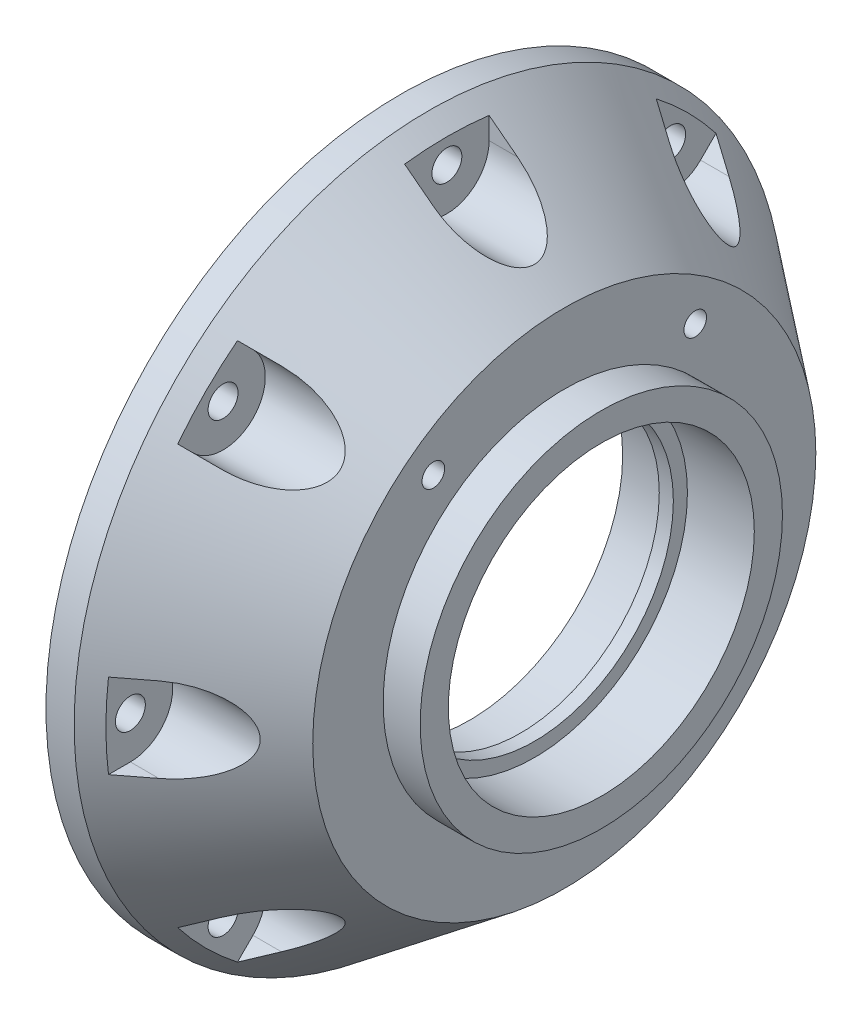
from build123d import *

# Parameters (mm, degrees)
FILLET1_R                       = 9.525
CUT_EXTRUDE1_START              = -10.414
CUT_EXTRUDE1_DEPTH              = 316.234767746
F_1_4_CLEARANCE_HOLE1_D         = 6.7564
F_1_4_20_TAPPED_HOLE1_D         = 5.1054
F_1_4_20_TAPPED_HOLE1_DEPTH     = 16.51
F_1_4_20_TAPPED_HOLE1_TIP       = 1.533816902
F_3_16_0_1875_DOWEL_HOLE1_D     = 4.7625
F_3_16_0_1875_DOWEL_HOLE1_DEPTH = 10.414
F_3_16_0_1875_DOWEL_HOLE1_TIP   = 1.430799349


with BuildPart() as part:
    # Sketch1 → Revolve1 (revolve)
    with BuildSketch(Plane.XY, mode=Mode.PRIVATE) as revolve1_sk:
        Polygon((462.47885273, 312.41), (468.82885273, 312.41), (499.37235273, 289.1409), (499.37235273, 273.2659), (507.72387273, 273.2659), (507.72387273, 266.9159), (492.64135273, 266.9159), (492.64135273, 263.7409), (489.46635273, 263.7409), (489.46635273, 266.9159), (478.03635273, 266.9159), (478.03635273, 294.259993653), (462.47885273, 294.259993653), align=None)
    revolve(revolve1_sk.sketch.rotate(Axis((596.9, 232.41, 0), (-1, 0, 0)), 90), axis=Axis((596.9, 232.41, 0), (-1, 0, 0)))

    # Fillet1
    fillet1_edges = [part.edges().sort_by_distance(p)[0] for p in [
        (478.03635273, 232.41, 61.849993653),
    ]]
    fillet(fillet1_edges, radius=FILLET1_R)

    # Sketch3 → Cut-Extrude1 (cut, through all)
    with BuildSketch(Plane.ZY.offset(-462.47885273).offset(CUT_EXTRUDE1_START)):
        with BuildLine():
            ThreePointArc((-9.525, 303.784993653), (0, 294.259993653), (9.525, 303.784993653))
            Line((9.525, 303.784993653), (9.525, 311.840940917))
            ThreePointArc((9.525, 311.840940917), (0, 312.41), (-9.525, 311.840940917))
            Line((-9.525, 311.840940917), (-9.525, 303.784993653))
        make_face()
        with BuildLine():
            ThreePointArc((62.901349049, 281.840964868), (56.568542495, 288.978542495), (49.430964868, 295.311349049))
            Line((49.430964868, 295.311349049), (43.734549928, 289.61493411))
            ThreePointArc((43.734549928, 289.61493411), (43.734549928, 276.144549928), (57.20493411, 276.144549928))
            Line((57.20493411, 276.144549928), (62.901349049, 281.840964868))
        make_face()
        with BuildLine():
            ThreePointArc((-57.20493411, 276.144549928), (-43.734549928, 276.144549928), (-43.734549928, 289.61493411))
            Line((-43.734549928, 289.61493411), (-49.430964868, 295.311349049))
            ThreePointArc((-49.430964868, 295.311349049), (-56.568542495, 288.978542495), (-62.901349049, 281.840964868))
            Line((-62.901349049, 281.840964868), (-57.20493411, 276.144549928))
        make_face()
        with BuildLine():
            ThreePointArc((71.374993653, 241.935), (61.849993653, 232.41), (71.374993653, 222.885))
            Line((71.374993653, 222.885), (79.430940917, 222.885))
            ThreePointArc((79.430940917, 222.885), (80, 232.41), (79.430940917, 241.935))
            Line((79.430940917, 241.935), (71.374993653, 241.935))
        make_face()
        with BuildLine():
            ThreePointArc((-71.374993653, 222.885), (-61.849993653, 232.41), (-71.374993653, 241.935))
            Line((-71.374993653, 241.935), (-79.430940917, 241.935))
            ThreePointArc((-79.430940917, 241.935), (-80, 232.41), (-79.430940917, 222.885))
            Line((-79.430940917, 222.885), (-71.374993653, 222.885))
        make_face()
        with BuildLine():
            ThreePointArc((57.20493411, 188.675450072), (43.734549928, 188.675450072), (43.734549928, 175.20506589))
            Line((43.734549928, 175.20506589), (49.430964868, 169.508650951))
            ThreePointArc((49.430964868, 169.508650951), (56.568542495, 175.841457505), (62.901349049, 182.979035132))
            Line((62.901349049, 182.979035132), (57.20493411, 188.675450072))
        make_face()
        with BuildLine():
            ThreePointArc((-43.734549928, 175.20506589), (-43.734549928, 188.675450072), (-57.20493411, 188.675450072))
            Line((-57.20493411, 188.675450072), (-62.901349049, 182.979035132))
            ThreePointArc((-62.901349049, 182.979035132), (-56.568542495, 175.841457505), (-49.430964868, 169.508650951))
            Line((-49.430964868, 169.508650951), (-43.734549928, 175.20506589))
        make_face()
        with BuildLine():
            ThreePointArc((9.525, 161.035006347), (0, 170.560006347), (-9.525, 161.035006347))
            Line((-9.525, 161.035006347), (-9.525, 152.979059083))
            ThreePointArc((-9.525, 152.979059083), (0, 152.41), (9.525, 152.979059083))
            Line((9.525, 152.979059083), (9.525, 161.035006347))
        make_face()
    extrude(amount=-CUT_EXTRUDE1_DEPTH, mode=Mode.SUBTRACT)

    # 1/4 Clearance Hole1 (through all)
    with Locations(Plane.ZY.offset(-462.47885273)):
        with Locations((0, 303.784993653), (50.469742019, 282.879742019), (71.374993653, 232.41), (50.469742019, 181.940257981), (0, 161.035006347), (-50.469742019, 181.940257981), (-71.374993653, 232.41), (-50.469742019, 282.879742019), (0, 232.41)):
            Hole(F_1_4_CLEARANCE_HOLE1_D / 2)

    # 1/4-20 Tapped Hole1
    with Locations(Plane(origin=(499.37235273, 271.254853292, 29.5275), x_dir=(0, 0, 1), z_dir=(1, 0, 0))):
        with Locations((0, 0), (-59.055, 0)):
            Hole(F_1_4_20_TAPPED_HOLE1_D / 2, depth=F_1_4_20_TAPPED_HOLE1_DEPTH)
            with Locations((0, 0, -(F_1_4_20_TAPPED_HOLE1_DEPTH + F_1_4_20_TAPPED_HOLE1_TIP / 2))):  # 118° drill point
                Cone(0, F_1_4_20_TAPPED_HOLE1_D / 2, F_1_4_20_TAPPED_HOLE1_TIP, mode=Mode.SUBTRACT)

    # 3/16 (0.1875) Dowel Hole1
    with Locations(Plane.ZY.offset(-462.47885273)):
        with Locations((-27.314027556, 166.468104231), (27.314027556, 298.351895769)):
            Hole(F_3_16_0_1875_DOWEL_HOLE1_D / 2, depth=F_3_16_0_1875_DOWEL_HOLE1_DEPTH)
            with Locations((0, 0, -(F_3_16_0_1875_DOWEL_HOLE1_DEPTH + F_3_16_0_1875_DOWEL_HOLE1_TIP / 2))):  # 118° drill point
                Cone(0, F_3_16_0_1875_DOWEL_HOLE1_D / 2, F_3_16_0_1875_DOWEL_HOLE1_TIP, mode=Mode.SUBTRACT)


solid = part.part
